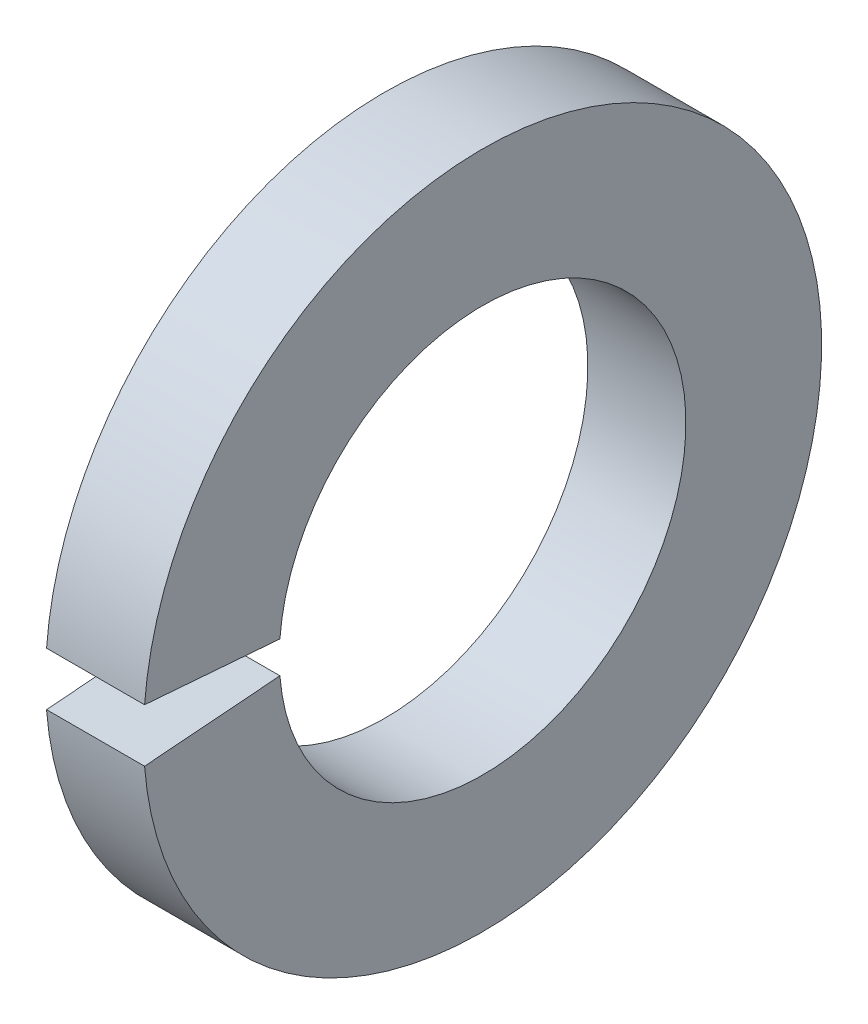
from build123d import *

# Parameters (mm, degrees)
SKETCH1_W = 3.9624
SKETCH1_H = 5.4864
GAP_DEPTH = 4.9624


with BuildPart() as part:
    # Sketch1 → Base-Revolve (revolve)
    with BuildSketch(Plane.XY):
        with Locations((-1.9812, 10.9601)):
            Rectangle(SKETCH1_W, SKETCH1_H)
    revolve(axis=Axis((-34.925, 0, 0), (1, 0, 0)))

    # Sketch2 → Gap (cut, through all)
    with BuildSketch(Plane(origin=(0, 0, 0), x_dir=(0, -1, 0), z_dir=(-1, 0, 0))):
        with BuildLine():
            Line((0, 0), (1.096651497, 13.934278445))
            ThreePointArc((1.096651497, 13.934278445), (0, 13.977366), (-1.096651497, 13.934278445))
            Line((-1.096651497, 13.934278445), (0, 0))
        make_face()
    extrude(amount=GAP_DEPTH, mode=Mode.SUBTRACT)


solid = part.part
